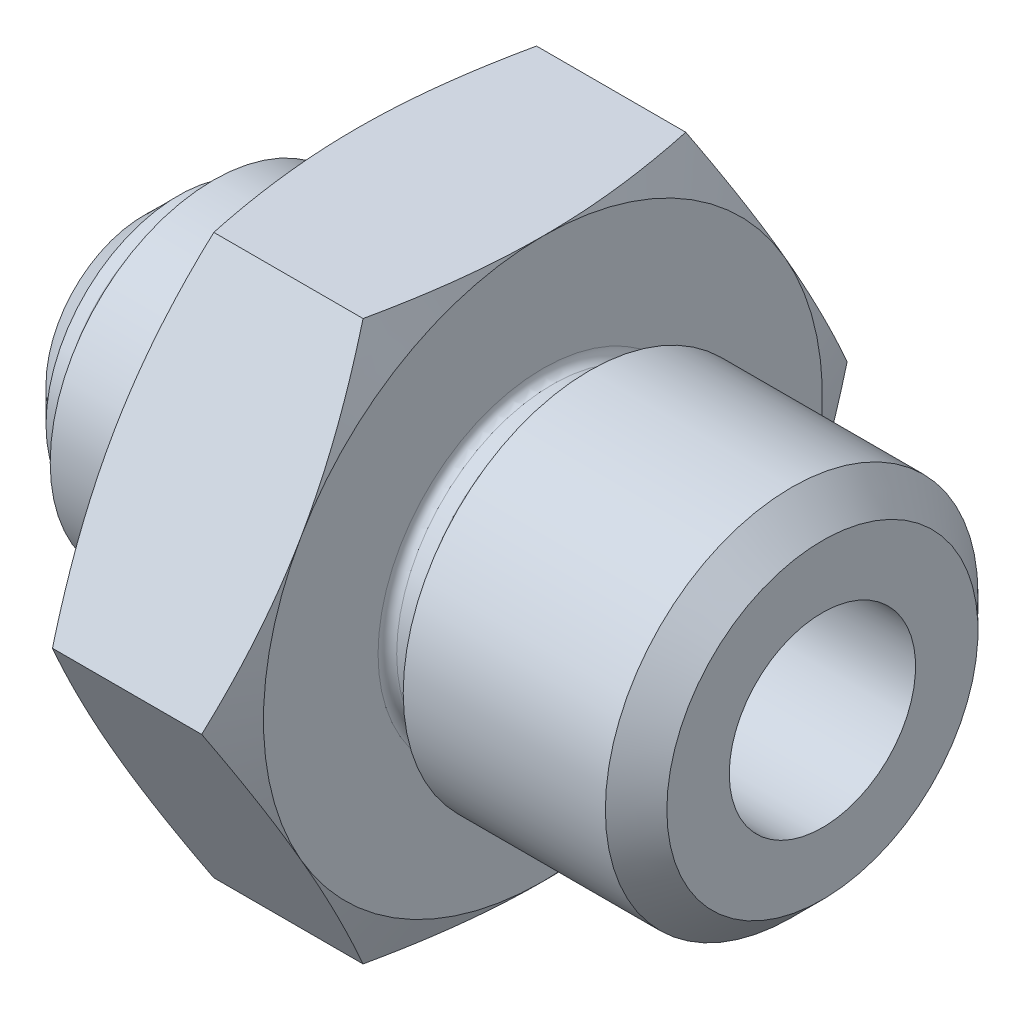
from build123d import *
from build123d.topology import SkipClean

# Parameters (mm, degrees)
CUT_EXTRUDE1_DEPTH = 34.496268449
CIRPATTERN1_COUNT  = 6


with BuildPart() as part:
    # Sketch1 → Revolve1 (revolve)
    with BuildSketch(Plane(origin=(0, 0, 0), x_dir=(1, 0, 0), z_dir=(0, 1, 0))):
        with BuildLine():
            Line((6.500562053, 7.08), (6.500562053, 12))
            Line((6.500562053, 12), (3.500562053, 19))
            Line((3.500562053, 19), (1.500562053, 19))
            Line((1.500562053, 19), (-1.499437947, 12))
            Line((-1.499437947, 12), (-1.499437947, 6.08031838))
            ThreePointArc((-1.499437947, 6.08031838), (-1.616595234, 5.797475668), (-1.899437947, 5.68031838))
            Line((-1.899437947, 5.68031838), (-2.544567646, 5.68031838))
            ThreePointArc((-2.544567646, 5.68031838), (-2.670163765, 5.700547903), (-2.783056135, 5.759190305))
            Line((-2.783056135, 5.759190305), (-3.499437947, 7))
            Line((-3.499437947, 7), (-7.656522503, 7))
            Line((-7.656522503, 7), (-8.366963495, 5.769480105))
            ThreePointArc((-8.366963495, 5.769480105), (-8.485178679, 5.703267117), (-8.618716483, 5.68031838))
            Line((-8.618716483, 5.68031838), (-9.156522503, 5.68031838))
            Line((-9.156522503, 5.68031838), (-10.636840883, 4.2))
            Line((-10.636840883, 4.2), (-10.636840883, 4))
            Line((-10.636840883, 4), (18.500562053, 4))
            Line((18.500562053, 4), (18.500562053, 6.68))
            Line((18.500562053, 6.68), (17.180562053, 8))
            Line((17.180562053, 8), (8.500562053, 8))
            Line((8.500562053, 8), (7.945301013, 7.038259666))
            ThreePointArc((7.945301013, 7.038259666), (7.81516358, 6.782765973), (7.547484793, 6.68))
            Line((7.547484793, 6.68), (6.900562053, 6.68))
            ThreePointArc((6.900562053, 6.68), (6.617719341, 6.797157288), (6.500562053, 7.08))
        make_face()
    revolve(axis=Axis((-84.410714624, 0, 0), (1, 0, 0)))

    # Sketch2 → Cut-Extrude1 (cut, symmetric)
    with SkipClean():  # the faces are left unmerged after this step: merging them gives an invalid solid
        with BuildSketch(Plane.ZY.offset(1.499437947)):
            Polygon((-116.355697184, 12), (-14.730919863, 12), (14.730919863, 12), (116.355697184, 12), (116.355697184, 215.249554642), (-116.355697184, 215.249554642), align=None)
        cut_extrude1 = extrude(amount=CUT_EXTRUDE1_DEPTH, both=True, mode=Mode.SUBTRACT)

    # CirPattern1: Cut-Extrude1 ×6 about axis
    cirpattern1_axis = Axis((-84.410714624, 0, 0), (1, 0, 0))
    for i in range(1, CIRPATTERN1_COUNT):
        add(cut_extrude1.rotate(cirpattern1_axis, i * 360 / CIRPATTERN1_COUNT), mode=Mode.SUBTRACT)


solid = part.part
